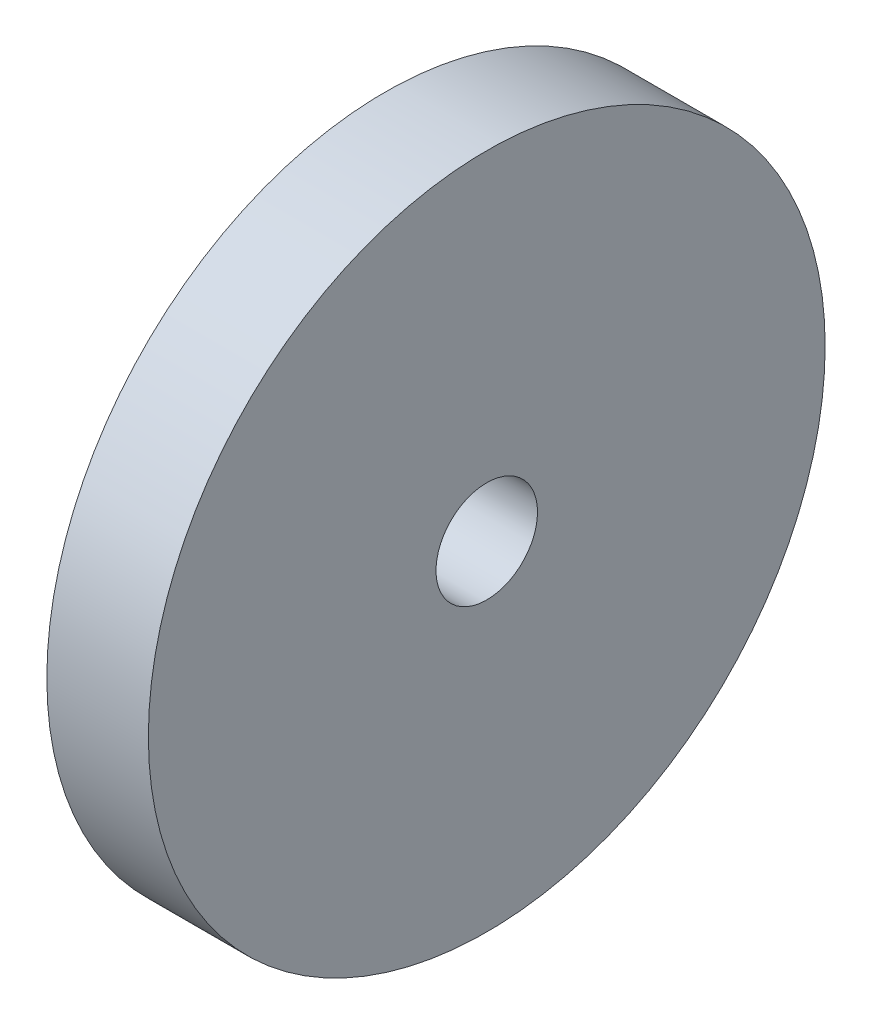
from build123d import *

# Parameters (mm, degrees)
SKETCH1_R           = 10
BOSS_EXTRUDE1_DEPTH = 3
SKETCH2_R           = 1.5
CUT_EXTRUDE1_DEPTH  = 4


with BuildPart() as part:
    # Sketch1 → Boss-Extrude1 (new body)
    with BuildSketch(Plane(origin=(0, 0, 0), x_dir=(0, 0, -1), z_dir=(1, 0, 0))):
        Circle(SKETCH1_R)
    extrude(amount=BOSS_EXTRUDE1_DEPTH)

    # Sketch2 → Cut-Extrude1 (cut, through all)
    with BuildSketch(Plane(origin=(3, 0, 0), x_dir=(0, 0, -1), z_dir=(1, 0, 0))):
        Circle(SKETCH2_R)
    extrude(amount=-CUT_EXTRUDE1_DEPTH, mode=Mode.SUBTRACT)


solid = part.part
